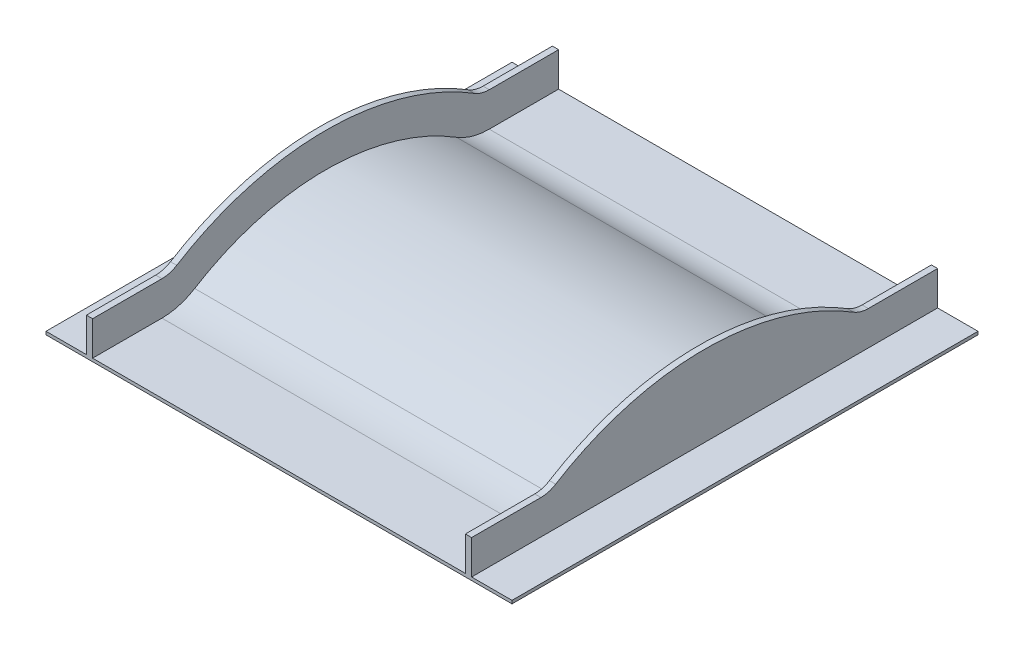
from build123d import *

# Parameters (mm, degrees)
SKETCH2_W           = 1500
SKETCH2_H           = 1500
BOSS_EXTRUDE1_DEPTH = 10
BOSS_EXTRUDE3_DEPTH = 1240
BOSS_EXTRUDE4_DEPTH = 20


with BuildPart() as part:
    # Sketch2 → Boss-Extrude1 (new body)
    with BuildSketch(Plane(origin=(0, 0, 0), x_dir=(1, 0, 0), z_dir=(0, 1, 0))):
        Rectangle(SKETCH2_W, SKETCH2_H)
    extrude(amount=BOSS_EXTRUDE1_DEPTH)

    # Sketch4 → Boss-Extrude3 (add)
    with BuildSketch(Plane.ZY.offset(620)):
        with BuildLine():
            ThreePointArc((-421.426148374, 40.000001079), (-472.010430907, 17.646159664), (-526.782687643, 10))
            Line((-526.782687643, 10), (-466.368952654, 10))
            ThreePointArc((-466.368952654, 10), (-444.150915082, 25.379564333), (-421.426148373, 40.000001079))
        make_face()
        with BuildLine():
            ThreePointArc((-421.426148373, 40.000001079), (-444.150915082, 25.379564333), (-466.368952654, 10))
            Line((-466.368952654, 10), (466.368952654, 10))
            ThreePointArc((466.368952654, 10), (444.150917669, 25.379562606), (421.426153659, 39.999997803))
            ThreePointArc((421.426153659, 39.999997803), (3.109e-06, 160), (-421.426148373, 40.000001079))
        make_face()
        with BuildLine():
            ThreePointArc((421.426153659, 39.999997803), (444.150917669, 25.379562606), (466.368952654, 10))
            Line((466.368952654, 10), (526.782687643, 10))
            ThreePointArc((526.782687643, 10), (472.010433898, 17.646158812), (421.426153659, 39.999997803))
        make_face()
    extrude(amount=-BOSS_EXTRUDE3_DEPTH)

    # Sketch5 → Boss-Extrude4 (add)
    with BuildSketch(Plane.ZY.offset(620)):
        with BuildLine():
            Line((-750, 120), (-750, 10))
            Line((-750, 10), (-526.782687643, 10))
            ThreePointArc((-526.782687643, 10), (-472.010431892, 17.646159383), (-421.426150114, 40))
            ThreePointArc((-421.426150114, 40), (-337.988327134, 85.095780378), (-249.799919936, 120))
            Line((-249.799919936, 120), (-526.782687643, 120))
            Line((-526.782687643, 120), (-750, 120))
        make_face()
        with BuildLine():
            ThreePointArc((-479.372245755, 133.5), (-502.135172555, 123.440771722), (-526.782687643, 120))
            Line((-526.782687643, 120), (-249.799919936, 120))
            ThreePointArc((-249.799919936, 120), (0, 160), (249.799919936, 120))
            Line((249.799919936, 120), (526.782687643, 120))
            ThreePointArc((526.782687643, 120), (502.135172555, 123.440771722), (479.372245755, 133.5))
            ThreePointArc((479.372245755, 133.5), (0, 270), (-479.372245755, 133.5))
        make_face()
        with BuildLine():
            ThreePointArc((421.426150114, 40), (472.010431892, 17.646159383), (526.782687643, 10))
            Line((526.782687643, 10), (750, 10))
            Line((750, 10), (750, 120))
            Line((750, 120), (526.782687643, 120))
            Line((526.782687643, 120), (249.799919936, 120))
            ThreePointArc((249.799919936, 120), (337.988327134, 85.095780378), (421.426150114, 40))
        make_face()
    boss_extrude4 = extrude(amount=-BOSS_EXTRUDE4_DEPTH)

    # Mirror1: Boss-Extrude4 across plane
    add(boss_extrude4.mirror(Plane(origin=(0, 0, 0), x_dir=(0, 0, 1), z_dir=(1, 0, 0))))


solid = part.part
